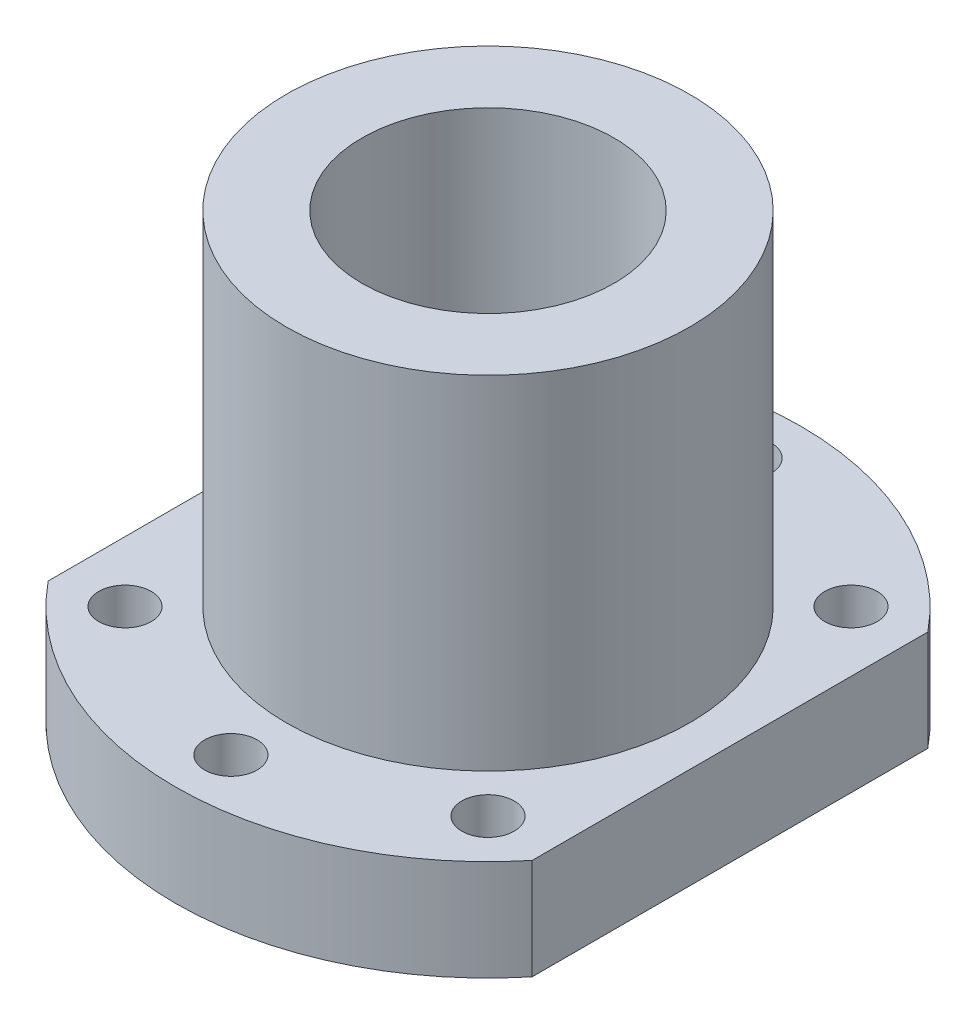
from build123d import *

# Parameters (mm, degrees)
SKETCH1_R           = 2.6
BOSS_EXTRUDE1_DEPTH = 10
SKETCH2_R           = 20
BOSS_EXTRUDE2_DEPTH = 34
CUT_EXTRUDE1_REACH  = 46
SKETCH3_R           = 12.5


with BuildPart() as part:
    # Sketch1 → Boss-Extrude1 (new body)
    with BuildSketch(Plane(origin=(0, 0, 0), x_dir=(1, 0, 0), z_dir=(0, 1, 0))):
        with BuildLine():
            Line((-24, 19.62141687), (-24, -19.62141687))
            ThreePointArc((-24, -19.62141687), (0, -31), (24, -19.62141687))
            Line((24, -19.62141687), (24, 19.62141687))
            ThreePointArc((24, 19.62141687), (0, 31), (-24, 19.62141687))
        make_face()
        with Locations((18, 18)):
            Circle(SKETCH1_R, mode=Mode.SUBTRACT)
        with Locations((0, 25.5)):
            Circle(SKETCH1_R, mode=Mode.SUBTRACT)
        with Locations((-18, 18)):
            Circle(SKETCH1_R, mode=Mode.SUBTRACT)
        with Locations((-18, -18)):
            Circle(SKETCH1_R, mode=Mode.SUBTRACT)
        with Locations((18, -18)):
            Circle(SKETCH1_R, mode=Mode.SUBTRACT)
        with Locations((0, -25.5)):
            Circle(SKETCH1_R, mode=Mode.SUBTRACT)
    extrude(amount=BOSS_EXTRUDE1_DEPTH)

    # Sketch2 → Boss-Extrude2 (add)
    with BuildSketch(Plane(origin=(0, 10, 0), x_dir=(1, 0, 0), z_dir=(0, 1, 0))):
        Circle(SKETCH2_R)
    extrude(amount=BOSS_EXTRUDE2_DEPTH)

    # Sketch3 → Cut-Extrude1 (cut, up to next)
    with BuildSketch(Plane(origin=(0, 44, 0), x_dir=(1, 0, 0), z_dir=(0, 1, 0)), mode=Mode.PRIVATE) as cut_extrude1_sk1:
        Circle(SKETCH3_R)
    cut_extrude1_tool1 = extrude(cut_extrude1_sk1.sketch, amount=-CUT_EXTRUDE1_REACH, mode=Mode.PRIVATE) & part.part
    add(cut_extrude1_tool1.solids().sort_by_distance((0, 44, 0))[0], mode=Mode.SUBTRACT)


solid = part.part
